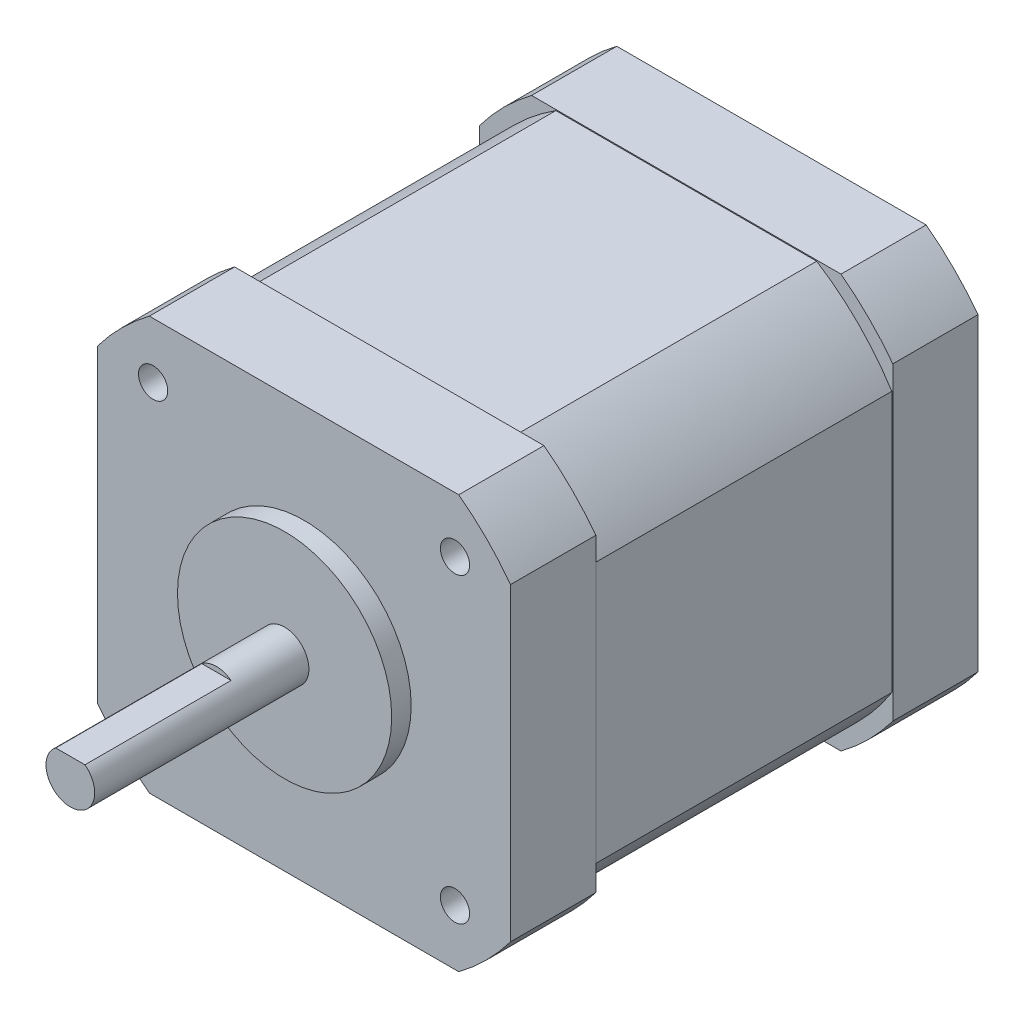
from build123d import *

# Parameters (mm, degrees)
SKETCH1_R                       = 2.5
BOSS_EXTRUDE1_DEPTH             = 24
SKETCH2_R                       = 11
BOSS_EXTRUDE2_DEPTH             = 2
SKETCH3_W                       = 42.418
SKETCH3_H                       = 42.418
BOSS_EXTRUDE3_DEPTH             = 48
CUT_EXTRUDE1_DEPTH              = 73
M3X0_5_TAPPED_HOLE1_D           = 2.5
M3X0_5_TAPPED_HOLE1_DEPTH       = 7.5
M3X0_5_TAPPED_HOLE1_CBORE_D     = 3
M3X0_5_TAPPED_HOLE1_CBORE_DEPTH = 6
M3X0_5_TAPPED_HOLE1_TIP         = 0.751075774
CUT_EXTRUDE2_DEPTH              = 15
CUT_EXTRUDE3_DEPTH              = 15.25


with BuildPart() as part:
    # Sketch1 → Boss-Extrude1 (new body)
    with BuildSketch(Plane.XY):
        Circle(SKETCH1_R)
    extrude(amount=BOSS_EXTRUDE1_DEPTH)

    # Sketch2 → Boss-Extrude2 (add)
    with BuildSketch(Plane(origin=(0, 0, 0), x_dir=(-1, 0, 0), z_dir=(0, 0, -1))):
        Circle(SKETCH2_R)
    extrude(amount=-BOSS_EXTRUDE2_DEPTH)

    # Sketch3 → Boss-Extrude3 (add)
    with BuildSketch(Plane(origin=(0, 0, 0), x_dir=(-1, 0, 0), z_dir=(0, 0, -1))):
        Rectangle(SKETCH3_W, SKETCH3_H)
    extrude(amount=BOSS_EXTRUDE3_DEPTH)

    # Sketch4 → Cut-Extrude1 (cut, through all)
    with BuildSketch(Plane(origin=(0, 0, -48), x_dir=(-1, 0, 0), z_dir=(0, 0, -1))):
        with BuildLine():
            Line((-21.209, -15.887992919), (-21.209, -21.209))
            Line((-21.209, -21.209), (-15.887992919, -21.209))
            ThreePointArc((-15.887992919, -21.209), (-18.738329701, -18.738329701), (-21.209, -15.887992919))
        make_face()
        with BuildLine():
            Line((15.887992919, -21.209), (21.209, -21.209))
            Line((21.209, -21.209), (21.209, -15.887992919))
            ThreePointArc((21.209, -15.887992919), (18.738329701, -18.738329701), (15.887992919, -21.209))
        make_face()
        with BuildLine():
            Line((21.209, 15.887992919), (21.209, 21.209))
            Line((21.209, 21.209), (15.887992919, 21.209))
            ThreePointArc((15.887992919, 21.209), (18.738329701, 18.738329701), (21.209, 15.887992919))
        make_face()
        with BuildLine():
            Line((-15.887992919, 21.209), (-21.209, 21.209))
            Line((-21.209, 21.209), (-21.209, 15.887992919))
            ThreePointArc((-21.209, 15.887992919), (-18.738329701, 18.738329701), (-15.887992919, 21.209))
        make_face()
    extrude(amount=-CUT_EXTRUDE1_DEPTH, mode=Mode.SUBTRACT)

    # M3x0.5 Tapped Hole1
    with Locations(Plane.XY):
        with Locations((-15.5, 15.5), (-15.5, -15.5), (15.5, -15.5), (15.5, 15.5)):
            CounterBoreHole(M3X0_5_TAPPED_HOLE1_D / 2, M3X0_5_TAPPED_HOLE1_CBORE_D / 2, M3X0_5_TAPPED_HOLE1_CBORE_DEPTH, depth=M3X0_5_TAPPED_HOLE1_DEPTH)
            with Locations((0, 0, -(M3X0_5_TAPPED_HOLE1_DEPTH + M3X0_5_TAPPED_HOLE1_TIP / 2))):  # 118° drill point
                Cone(0, M3X0_5_TAPPED_HOLE1_D / 2, M3X0_5_TAPPED_HOLE1_TIP, mode=Mode.SUBTRACT)

    # Sketch7 → Cut-Extrude2 (cut)
    with BuildSketch(Plane.XY.offset(24)):
        with BuildLine():
            Line((-1.5, 2), (1.5, 2))
            ThreePointArc((1.5, 2), (0, 2.5), (-1.5, 2))
        make_face()
    extrude(amount=-CUT_EXTRUDE2_DEPTH, mode=Mode.SUBTRACT)

    # Sketch8 → Cut-Extrude3 (cut, symmetric)
    with BuildSketch(Plane.XY.offset(-24)):
        with BuildLine():
            Line((15.887992919, 21.209), (-15.887992919, 21.209))
            ThreePointArc((-15.887992919, 21.209), (-18.738329701, 18.738329701), (-21.209, 15.887992919))
            Line((-21.209, 15.887992919), (-21.209, -15.887992919))
            ThreePointArc((-21.209, -15.887992919), (-18.738329701, -18.738329701), (-15.887992919, -21.209))
            Line((-15.887992919, -21.209), (15.887992919, -21.209))
            ThreePointArc((15.887992919, -21.209), (18.738329701, -18.738329701), (21.209, -15.887992919))
            Line((21.209, -15.887992919), (21.209, 15.887992919))
            ThreePointArc((21.209, 15.887992919), (18.738329701, 18.738329701), (15.887992919, 21.209))
        make_face()
        with BuildLine():
            Line((-13.394406258, 21.109), (13.394406258, 21.109))
            ThreePointArc((13.394406258, 21.109), (17.67766953, 17.67766953), (21.109, 13.394406258))
            Line((21.109, 13.394406258), (21.109, -13.394406258))
            ThreePointArc((21.109, -13.394406258), (17.67766953, -17.67766953), (13.394406258, -21.109))
            Line((13.394406258, -21.109), (-13.394406258, -21.109))
            ThreePointArc((-13.394406258, -21.109), (-17.67766953, -17.67766953), (-21.109, -13.394406258))
            Line((-21.109, -13.394406258), (-21.109, 13.394406258))
            ThreePointArc((-21.109, 13.394406258), (-17.67766953, 17.67766953), (-13.394406258, 21.109))
        make_face(mode=Mode.SUBTRACT)
    extrude(amount=CUT_EXTRUDE3_DEPTH, both=True, mode=Mode.SUBTRACT)


solid = part.part
